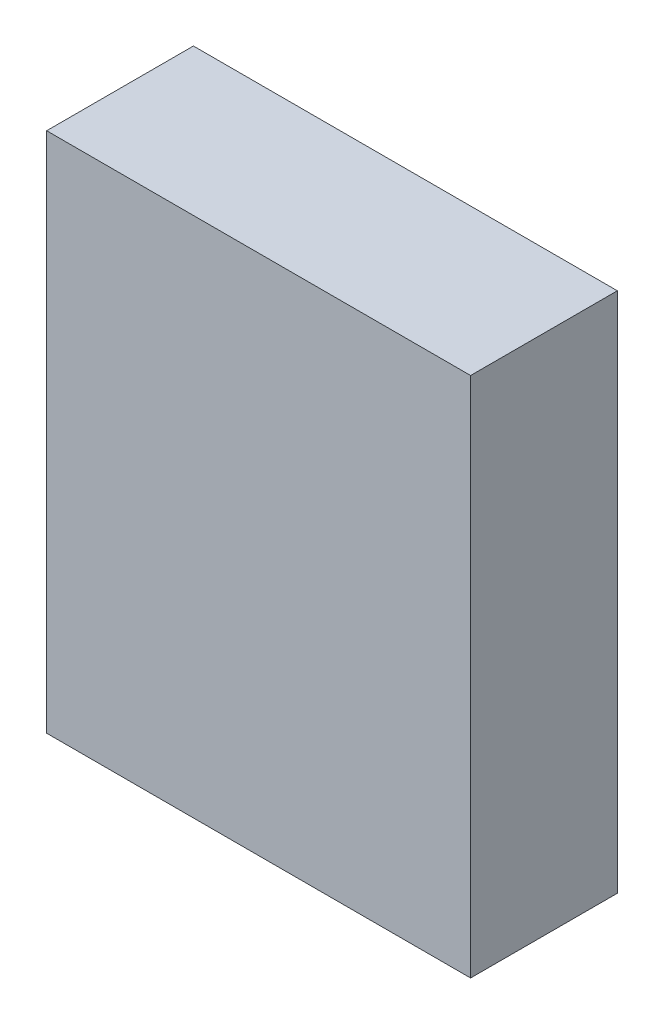
from build123d import *

# Parameters (mm, degrees)
SKETCH1_W           = 26
SKETCH1_H           = 32
BOSS_EXTRUDE1_DEPTH = 9


with BuildPart() as part:
    # Sketch1 → Boss-Extrude1 (new body)
    with BuildSketch(Plane.XY):
        with Locations((13, -16)):
            Rectangle(SKETCH1_W, SKETCH1_H)
    extrude(amount=BOSS_EXTRUDE1_DEPTH)


solid = part.part
